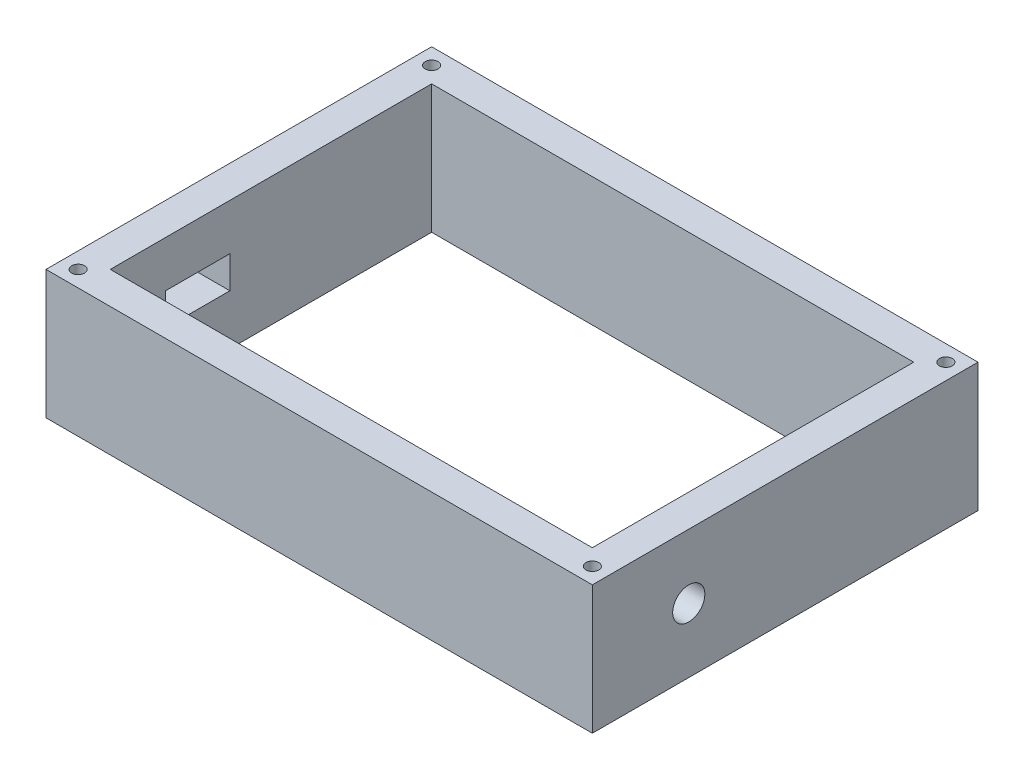
from build123d import *

# Parameters (mm, degrees)
SKETCH1_W                 = 170
SKETCH1_H                 = 120
SKETCH1_W_2               = 150
SKETCH1_H_2               = 100
EXTRUDE_THIN1_DEPTH       = 40
SKETCH2_R                 = 5
CUT_EXTRUDE1_DEPTH        = 10
F_4_0MM_DOWEL_HOLE1_D     = 4
F_4_0MM_DOWEL_HOLE1_DEPTH = 5
F_4_0MM_DOWEL_HOLE1_TIP   = 1.201721238
F_4_0MM_DOWEL_HOLE2_D     = 4
F_4_0MM_DOWEL_HOLE2_DEPTH = 5
F_4_0MM_DOWEL_HOLE2_TIP   = 1.201721238
F_4_0MM_DOWEL_HOLE3_D     = 4
F_4_0MM_DOWEL_HOLE3_DEPTH = 5
F_4_0MM_DOWEL_HOLE3_TIP   = 1.201721238
F_4_0MM_DOWEL_HOLE4_D     = 4
F_4_0MM_DOWEL_HOLE4_DEPTH = 5
F_4_0MM_DOWEL_HOLE4_TIP   = 1.201721238
SKETCH15_W                = 20
SKETCH15_H                = 10
CUT_EXTRUDE7_DEPTH        = 10


with BuildPart() as part:
    # Sketch1 → Extrude-Thin1 (new body)
    with BuildSketch(Plane(origin=(0, 0, 0), x_dir=(1, 0, 0), z_dir=(0, 1, 0))):
        Rectangle(SKETCH1_W, SKETCH1_H)
        Rectangle(SKETCH1_W_2, SKETCH1_H_2, mode=Mode.SUBTRACT)
    extrude(amount=EXTRUDE_THIN1_DEPTH)

    # Sketch2 → Cut-Extrude1 (cut)
    with BuildSketch(Plane(origin=(85, 0, 0), x_dir=(0, 0, -1), z_dir=(1, 0, 0))):
        with Locations((-30, 20)):
            Circle(SKETCH2_R)
    extrude(amount=-CUT_EXTRUDE1_DEPTH, mode=Mode.SUBTRACT)

    # Ø4.0mm Dowel Hole1
    with Locations(Plane(origin=(0, 40, 0), x_dir=(1, 0, 0), z_dir=(0, 1, 0))):
        with Locations((-80, 55)):
            Hole(F_4_0MM_DOWEL_HOLE1_D / 2, depth=F_4_0MM_DOWEL_HOLE1_DEPTH)
            with Locations((0, 0, -(F_4_0MM_DOWEL_HOLE1_DEPTH + F_4_0MM_DOWEL_HOLE1_TIP / 2))):  # 118° drill point
                Cone(0, F_4_0MM_DOWEL_HOLE1_D / 2, F_4_0MM_DOWEL_HOLE1_TIP, mode=Mode.SUBTRACT)

    # Ø4.0mm Dowel Hole2
    with Locations(Plane(origin=(0, 40, 0), x_dir=(1, 0, 0), z_dir=(0, 1, 0))):
        with Locations((-80, -55)):
            Hole(F_4_0MM_DOWEL_HOLE2_D / 2, depth=F_4_0MM_DOWEL_HOLE2_DEPTH)
            with Locations((0, 0, -(F_4_0MM_DOWEL_HOLE2_DEPTH + F_4_0MM_DOWEL_HOLE2_TIP / 2))):  # 118° drill point
                Cone(0, F_4_0MM_DOWEL_HOLE2_D / 2, F_4_0MM_DOWEL_HOLE2_TIP, mode=Mode.SUBTRACT)

    # Ø4.0mm Dowel Hole3
    with Locations(Plane(origin=(0, 40, 0), x_dir=(1, 0, 0), z_dir=(0, 1, 0))):
        with Locations((80, -55)):
            Hole(F_4_0MM_DOWEL_HOLE3_D / 2, depth=F_4_0MM_DOWEL_HOLE3_DEPTH)
            with Locations((0, 0, -(F_4_0MM_DOWEL_HOLE3_DEPTH + F_4_0MM_DOWEL_HOLE3_TIP / 2))):  # 118° drill point
                Cone(0, F_4_0MM_DOWEL_HOLE3_D / 2, F_4_0MM_DOWEL_HOLE3_TIP, mode=Mode.SUBTRACT)

    # Ø4.0mm Dowel Hole4
    with Locations(Plane(origin=(0, 40, 0), x_dir=(1, 0, 0), z_dir=(0, 1, 0))):
        with Locations((80, 55)):
            Hole(F_4_0MM_DOWEL_HOLE4_D / 2, depth=F_4_0MM_DOWEL_HOLE4_DEPTH)
            with Locations((0, 0, -(F_4_0MM_DOWEL_HOLE4_DEPTH + F_4_0MM_DOWEL_HOLE4_TIP / 2))):  # 118° drill point
                Cone(0, F_4_0MM_DOWEL_HOLE4_D / 2, F_4_0MM_DOWEL_HOLE4_TIP, mode=Mode.SUBTRACT)

    # Sketch15 → Cut-Extrude7 (cut)
    with BuildSketch(Plane.ZY.offset(85)):
        with Locations((22.785330455, 20.631239888)):
            Rectangle(SKETCH15_W, SKETCH15_H)
    extrude(amount=-CUT_EXTRUDE7_DEPTH, mode=Mode.SUBTRACT)


solid = part.part
